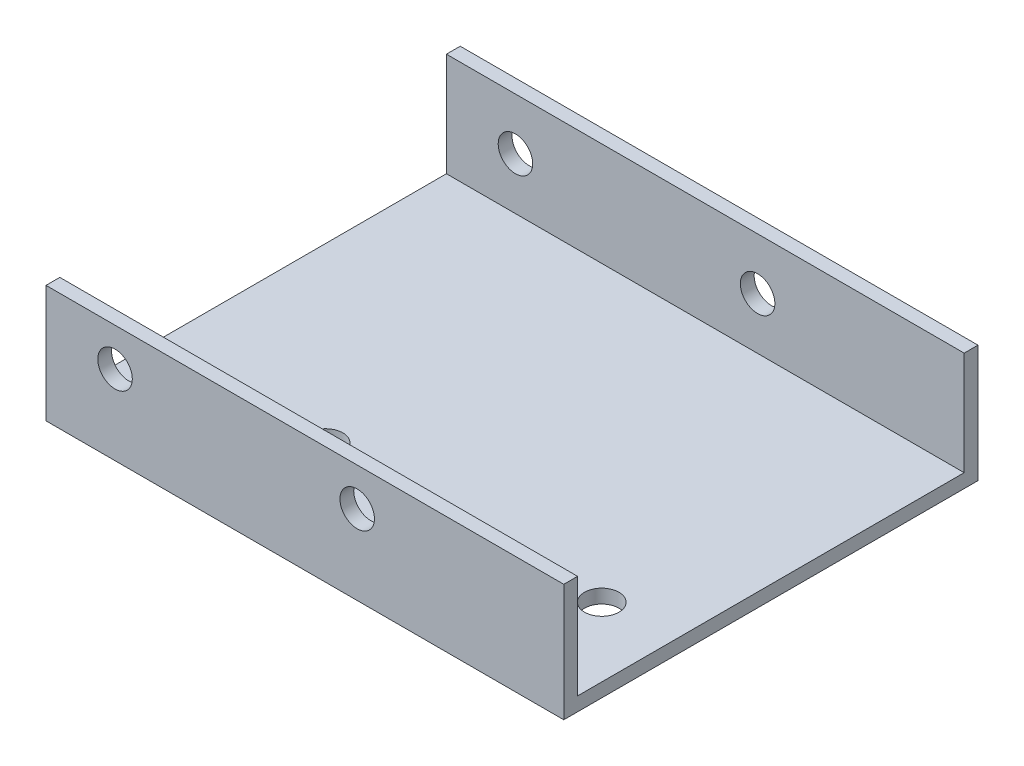
from build123d import *

# Parameters (mm, degrees)
ESBO_O1_W                = 75
ESBO_O1_H                = 56
RESSALTO_EXTRUS_O1_DEPTH = 2
ESBO_O3_W                = 75
ESBO_O3_H                = 17
RESSALTO_EXTRUS_O3_DEPTH = 2
CORTE_EXTRUS_O1_REACH    = 4
ESBO_O4_R                = 2.5
CORTE_EXTRUS_O2_REACH    = 62
ESBO_O5_R                = 2.5
ESBO_O6_R                = 2.5
CORTE_EXTRUS_O3_DEPTH    = 2
CUT_EXTRUDE1_REACH       = 62
SKETCH1_R                = 2.5
CUT_EXTRUDE2_REACH       = 62
SKETCH2_R                = 2.5


with BuildPart() as part:
    # Esboço1 → Ressalto-extrusão1 (new body)
    with BuildSketch(Plane(origin=(0, 0, 0), x_dir=(1, 0, 0), z_dir=(0, 1, 0))):
        Rectangle(ESBO_O1_W, ESBO_O1_H)
    extrude(amount=RESSALTO_EXTRUS_O1_DEPTH)

    # Esboço3 → Ressalto-extrusão3 (add)
    with BuildSketch(Plane.XY.offset(28)):
        with Locations((0, 8.5)):
            Rectangle(ESBO_O3_W, ESBO_O3_H)
    ressalto_extrus_o3 = extrude(amount=RESSALTO_EXTRUS_O3_DEPTH)

    # Espelhar2: Ressalto-extrusão3 across plane
    add(ressalto_extrus_o3.mirror(Plane.XY))

    # Esboço4 → Corte-extrusão1 (cut, up to next)
    with BuildSketch(Plane(origin=(0, 0, 28), x_dir=(-1, 0, 0), z_dir=(0, 0, -1)), mode=Mode.PRIVATE) as corte_extrus_o1_sk1:
        with Locations((-7.575, 11.5)):
            Circle(ESBO_O4_R)
    corte_extrus_o1_tool1 = extrude(corte_extrus_o1_sk1.sketch, amount=-CORTE_EXTRUS_O1_REACH, mode=Mode.PRIVATE) & part.part
    add(corte_extrus_o1_tool1.solids().sort_by_distance((7.575, 11.5, 28))[0], mode=Mode.SUBTRACT)

    # Esboço5 → Corte-extrusão2 (cut, up to next)
    with BuildSketch(Plane.XY.offset(30), mode=Mode.PRIVATE) as corte_extrus_o2_sk1:
        with Locations((-27.5, 11.5)):
            Circle(ESBO_O5_R)
    corte_extrus_o2_tool1 = extrude(corte_extrus_o2_sk1.sketch, amount=-CORTE_EXTRUS_O2_REACH, mode=Mode.PRIVATE) & part.part
    add(corte_extrus_o2_tool1.solids().sort_by_distance((-27.5, 11.5, 30))[0], mode=Mode.SUBTRACT)

    # Esboço6 → Corte-extrusão3 (cut)
    with BuildSketch(Plane(origin=(0, 2, 0), x_dir=(1, 0, 0), z_dir=(0, 1, 0))):
        with Locations((-12.5, -14.5)):
            Circle(ESBO_O6_R)
        with Locations((27.5, -14.5)):
            Circle(ESBO_O6_R)
    extrude(amount=-CORTE_EXTRUS_O3_DEPTH, mode=Mode.SUBTRACT)

    # Sketch1 → Cut-Extrude1 (cut, up to next)
    with BuildSketch(Plane(origin=(0, 0, -30), x_dir=(-1, 0, 0), z_dir=(0, 0, -1)), mode=Mode.PRIVATE) as cut_extrude1_sk1:
        with Locations((-7.575, 9.5)):
            Circle(SKETCH1_R)
    cut_extrude1_tool1 = extrude(cut_extrude1_sk1.sketch, amount=-CUT_EXTRUDE1_REACH, mode=Mode.PRIVATE) & part.part
    add(cut_extrude1_tool1.solids().sort_by_distance((7.575, 9.5, -30))[0], mode=Mode.SUBTRACT)

    # Sketch2 → Cut-Extrude2 (cut, up to next)
    with BuildSketch(Plane(origin=(0, 0, -30), x_dir=(-1, 0, 0), z_dir=(0, 0, -1)), mode=Mode.PRIVATE) as cut_extrude2_sk1:
        with Locations((27.5, 9.5)):
            Circle(SKETCH2_R)
    cut_extrude2_tool1 = extrude(cut_extrude2_sk1.sketch, amount=-CUT_EXTRUDE2_REACH, mode=Mode.PRIVATE) & part.part
    add(cut_extrude2_tool1.solids().sort_by_distance((-27.5, 9.5, -30))[0], mode=Mode.SUBTRACT)


solid = part.part
